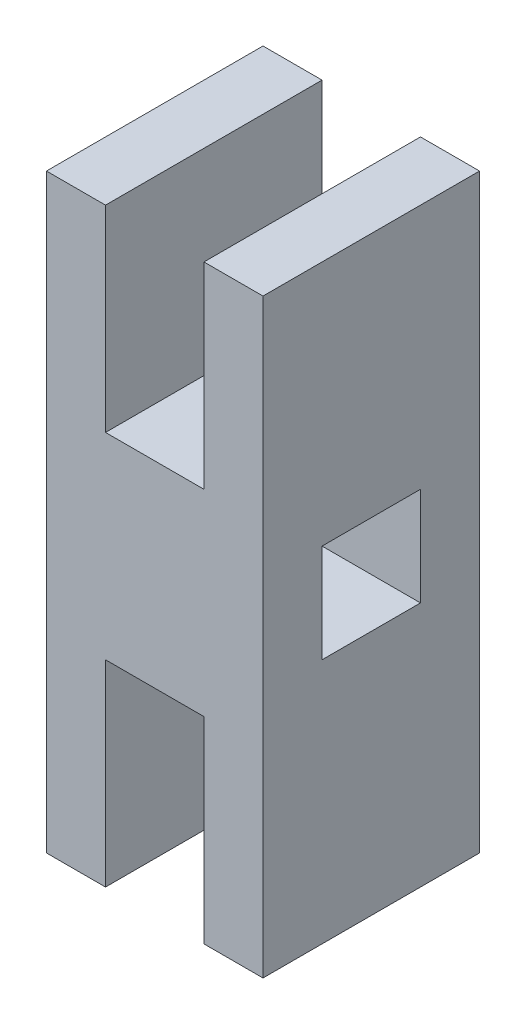
from build123d import *

# Parameters (mm, degrees)
BOSS_EXTRUDE1_DEPTH      = 10
BOSS_EXTRUDE1_DEPTH_BACK = 1
SKETCH2_W                = 5
SKETCH2_H                = 5
CUT_EXTRUDE1_DEPTH       = 1
CUT_EXTRUDE1_DEPTH_BACK  = 12


with BuildPart() as part:
    # Sketch1 → Boss-Extrude1 (new body, two sides)
    with BuildSketch(Plane.XY) as boss_extrude1_sk:
        Polygon((-2.5, 5), (2.5, 5), (2.5, 15), (5.5, 15), (5.5, -15), (2.5, -15), (2.5, -5), (-2.5, -5), (-2.5, -15), (-5.5, -15), (-5.5, 15), (-2.5, 15), align=None)
    extrude(amount=BOSS_EXTRUDE1_DEPTH)
    extrude(boss_extrude1_sk.sketch, amount=-BOSS_EXTRUDE1_DEPTH_BACK)

    # Sketch2 → Cut-Extrude1 (cut, two sides)
    with BuildSketch(Plane(origin=(5.5, 0, 0), x_dir=(0, 0, -1), z_dir=(1, 0, 0))) as cut_extrude1_sk:
        with Locations((-4.5, 0)):
            Rectangle(SKETCH2_W, SKETCH2_H)
    extrude(amount=CUT_EXTRUDE1_DEPTH, mode=Mode.SUBTRACT)
    extrude(cut_extrude1_sk.sketch, amount=-CUT_EXTRUDE1_DEPTH_BACK, mode=Mode.SUBTRACT)


solid = part.part
